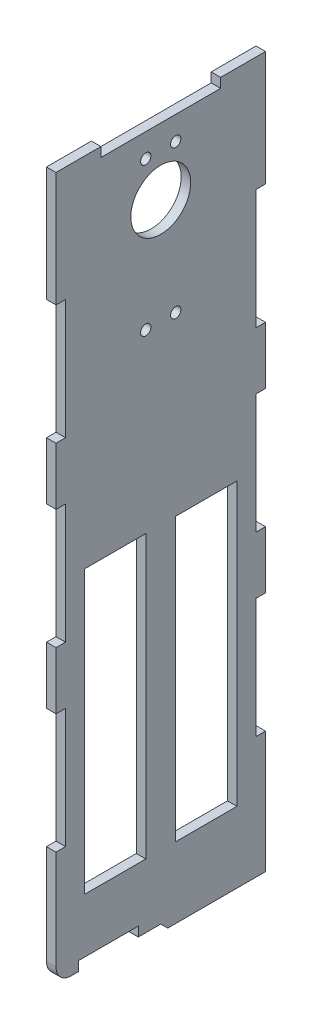
from build123d import *

# Parameters (mm, degrees)
SKETCH2_W           = 20.475
SKETCH2_H           = 94.165655299
SKETCH2_R           = 1.725
SKETCH2_R_2         = 10
BOSS_EXTRUDE1_DEPTH = 3.175
SKETCH3_W           = 3.175
SKETCH3_H           = 40
SKETCH3_H_2         = 20
SKETCH3_W_2         = 40
SKETCH3_H_3         = 3.175
SKETCH3_W_3         = 20
CUT_EXTRUDE1_DEPTH  = 10
FILLET1_R           = 5


with BuildPart() as part:
    # Sketch2 → Boss-Extrude1 (new body)
    with BuildSketch(Plane(origin=(0, 0, 0), x_dir=(0, 0, -1), z_dir=(1, 0, 0))):
        Polygon((35, -119.825), (35, 117.5), (-35, 117.5), (-35, -117.5), (0, -117.5), (2.325, -119.825), align=None)
        with Locations((-15.2375, -49.067172351)):
            Rectangle(SKETCH2_W, SKETCH2_H, mode=Mode.SUBTRACT)
        with Locations((15.2375, -49.067172351)):
            Rectangle(SKETCH2_W, SKETCH2_H, mode=Mode.SUBTRACT)
        with Locations((5, 56.954767415)):
            Circle(SKETCH2_R, mode=Mode.SUBTRACT)
        with Locations((-5, 56.954767415)):
            Circle(SKETCH2_R, mode=Mode.SUBTRACT)
        with Locations((-5, 106.454767415)):
            Circle(SKETCH2_R, mode=Mode.SUBTRACT)
        with Locations((5, 106.454767415)):
            Circle(SKETCH2_R, mode=Mode.SUBTRACT)
        with Locations((0, 92.104767415)):
            Circle(SKETCH2_R_2, mode=Mode.SUBTRACT)
    extrude(amount=BOSS_EXTRUDE1_DEPTH)

    # Sketch3 → Cut-Extrude1 (cut)
    with BuildSketch(Plane.ZY):
        with Locations((-33.4125, 59.155293611)):
            Rectangle(SKETCH3_W, SKETCH3_H)
        with Locations((33.4125, 59.155293611)):
            Rectangle(SKETCH3_W, SKETCH3_H)
        with Locations((33.4125, 10)):
            Rectangle(SKETCH3_W, SKETCH3_H_2)
        with Locations((-33.4125, 10)):
            Rectangle(SKETCH3_W, SKETCH3_H_2)
        with Locations((-33.4125, -10)):
            Rectangle(SKETCH3_W, SKETCH3_H_2)
        with Locations((33.4125, -10)):
            Rectangle(SKETCH3_W, SKETCH3_H_2)
        with Locations((33.4125, -59.155293611)):
            Rectangle(SKETCH3_W, SKETCH3_H)
        with Locations((-33.4125, -59.155293611)):
            Rectangle(SKETCH3_W, SKETCH3_H)
        with Locations((0, 115.9125)):
            Rectangle(SKETCH3_W_2, SKETCH3_H_3)
        with Locations((17.5, -115.9125)):
            Rectangle(SKETCH3_W_3, SKETCH3_H_3)
    extrude(amount=-CUT_EXTRUDE1_DEPTH, mode=Mode.SUBTRACT)

    # Fillet1
    fillet1_edges = [part.edges().sort_by_distance(p)[0] for p in [
        (1.5875, -117.5, 35),
    ]]
    fillet(fillet1_edges, radius=FILLET1_R)


solid = part.part
